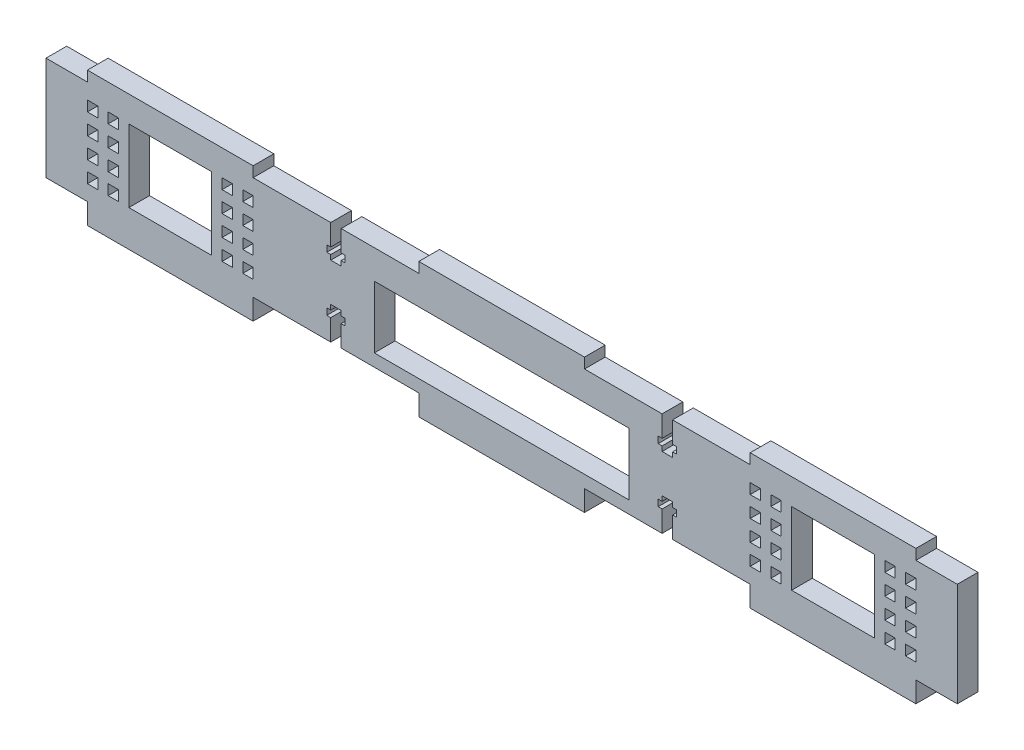
from build123d import *

# Parameters (mm, degrees)
BASEEXTRUDE_DEPTH  = 6.35
SCREWCUTS_DEPTH    = 7.35
SKETCH3_W          = 78.08
SKETCH3_H          = 19.05
SKETCH3_W_2        = 25.4
SKETCH3_H_2        = 22.225
CUT_EXTRUDE1_DEPTH = 7.35
SKETCH4_W          = 3.175
SKETCH4_H          = 3.175
CUT_EXTRUDE2_DEPTH = 7.35


with BuildPart() as part:
    # Sketch1 → BaseExtrude (new body)
    with BuildSketch(Plane.XY):
        Polygon((0, 0), (12.7, 0), (12.7, -6.35), (63.5, -6.35), (63.5, 0), (114.3, 0), (114.3, -6.35), (165.1, -6.35), (165.1, 0), (215.9, 0), (215.9, -6.35), (266.7, -6.35), (266.7, 0), (279.4, 0), (279.4, 31.75), (266.7, 31.75), (266.7, 34.925), (215.9, 34.925), (215.9, 31.75), (165.1, 31.75), (165.1, 34.925), (114.3, 34.925), (114.3, 31.75), (63.5, 31.75), (63.5, 34.925), (12.7, 34.925), (12.7, 31.75), (0, 31.75), align=None)
    extrude(amount=BASEEXTRUDE_DEPTH)

    # Sketch2 → ScrewCuts (cut, through all)
    with BuildSketch(Plane.XY.offset(6.35)):
        Polygon((90.5, 31.75), (87.3, 31.75), (87.3, 25.25), (86.1, 25.25), (86.1, 23.25), (87.3, 23.25), (87.3, 21.75), (90.5, 21.75), (90.5, 23.25), (91.7, 23.25), (91.7, 25.25), (90.5, 25.25), align=None)
        Polygon((87.3, 8.5), (87.3, 10), (90.5, 10), (90.5, 8.5), (91.7, 8.5), (91.7, 6.5), (90.5, 6.5), (90.5, 0), (87.3, 0), (87.3, 6.5), (86.1, 6.5), (86.1, 8.5), align=None)
        Polygon((188.9, 0), (192.1, 0), (192.1, 6.5), (193.3, 6.5), (193.3, 8.5), (192.1, 8.5), (192.1, 10), (188.9, 10), (188.9, 8.5), (187.7, 8.5), (187.7, 6.5), (188.9, 6.5), align=None)
        Polygon((192.1, 23.25), (192.1, 21.75), (188.9, 21.75), (188.9, 23.25), (187.7, 23.25), (187.7, 25.25), (188.9, 25.25), (188.9, 31.75), (192.1, 31.75), (192.1, 25.25), (193.3, 25.25), (193.3, 23.25), align=None)
    extrude(amount=-SCREWCUTS_DEPTH, mode=Mode.SUBTRACT)

    # Sketch3 → Cut-Extrude1 (cut, through all)
    with BuildSketch(Plane.XY.offset(6.35)):
        with Locations((139.7, 13.335)):
            Rectangle(SKETCH3_W, SKETCH3_H)
        with Locations((38.1, 15.875)):
            Rectangle(SKETCH3_W_2, SKETCH3_H_2)
        with Locations((241.3, 15.875)):
            Rectangle(SKETCH3_W_2, SKETCH3_H_2)
    extrude(amount=-CUT_EXTRUDE1_DEPTH, mode=Mode.SUBTRACT)

    # Sketch4 → Cut-Extrude2 (cut, through all)
    with BuildSketch(Plane.XY.offset(6.35)):
        with Locations((20.6375, 25.4)):
            Rectangle(SKETCH4_W, SKETCH4_H)
        with Locations((20.6375, 19.05)):
            Rectangle(SKETCH4_W, SKETCH4_H)
        with Locations((14.2875, 25.4)):
            Rectangle(SKETCH4_W, SKETCH4_H)
        with Locations((14.2875, 19.05)):
            Rectangle(SKETCH4_W, SKETCH4_H)
        with Locations((20.6375, 12.7)):
            Rectangle(SKETCH4_W, SKETCH4_H)
        with Locations((14.2875, 12.7)):
            Rectangle(SKETCH4_W, SKETCH4_H)
        with Locations((20.6375, 6.35)):
            Rectangle(SKETCH4_W, SKETCH4_H)
        with Locations((14.2875, 6.35)):
            Rectangle(SKETCH4_W, SKETCH4_H)
        with Locations((61.9125, 6.35)):
            Rectangle(SKETCH4_W, SKETCH4_H)
        with Locations((55.5625, 6.35)):
            Rectangle(SKETCH4_W, SKETCH4_H)
        with Locations((61.9125, 12.7)):
            Rectangle(SKETCH4_W, SKETCH4_H)
        with Locations((55.5625, 12.7)):
            Rectangle(SKETCH4_W, SKETCH4_H)
        with Locations((61.9125, 19.05)):
            Rectangle(SKETCH4_W, SKETCH4_H)
        with Locations((55.5625, 19.05)):
            Rectangle(SKETCH4_W, SKETCH4_H)
        with Locations((61.9125, 25.4)):
            Rectangle(SKETCH4_W, SKETCH4_H)
        with Locations((55.5625, 25.4)):
            Rectangle(SKETCH4_W, SKETCH4_H)
        with Locations((223.8375, 25.4)):
            Rectangle(SKETCH4_W, SKETCH4_H)
        with Locations((223.8375, 19.05)):
            Rectangle(SKETCH4_W, SKETCH4_H)
        with Locations((217.4875, 25.4)):
            Rectangle(SKETCH4_W, SKETCH4_H)
        with Locations((217.4875, 19.05)):
            Rectangle(SKETCH4_W, SKETCH4_H)
        with Locations((223.8375, 12.7)):
            Rectangle(SKETCH4_W, SKETCH4_H)
        with Locations((217.4875, 12.7)):
            Rectangle(SKETCH4_W, SKETCH4_H)
        with Locations((223.8375, 6.35)):
            Rectangle(SKETCH4_W, SKETCH4_H)
        with Locations((217.4875, 6.35)):
            Rectangle(SKETCH4_W, SKETCH4_H)
        with Locations((265.1125, 6.35)):
            Rectangle(SKETCH4_W, SKETCH4_H)
        with Locations((258.7625, 6.35)):
            Rectangle(SKETCH4_W, SKETCH4_H)
        with Locations((265.1125, 12.7)):
            Rectangle(SKETCH4_W, SKETCH4_H)
        with Locations((258.7625, 12.7)):
            Rectangle(SKETCH4_W, SKETCH4_H)
        with Locations((265.1125, 19.05)):
            Rectangle(SKETCH4_W, SKETCH4_H)
        with Locations((258.7625, 19.05)):
            Rectangle(SKETCH4_W, SKETCH4_H)
        with Locations((265.1125, 25.4)):
            Rectangle(SKETCH4_W, SKETCH4_H)
        with Locations((258.7625, 25.4)):
            Rectangle(SKETCH4_W, SKETCH4_H)
    extrude(amount=-CUT_EXTRUDE2_DEPTH, mode=Mode.SUBTRACT)


solid = part.part
